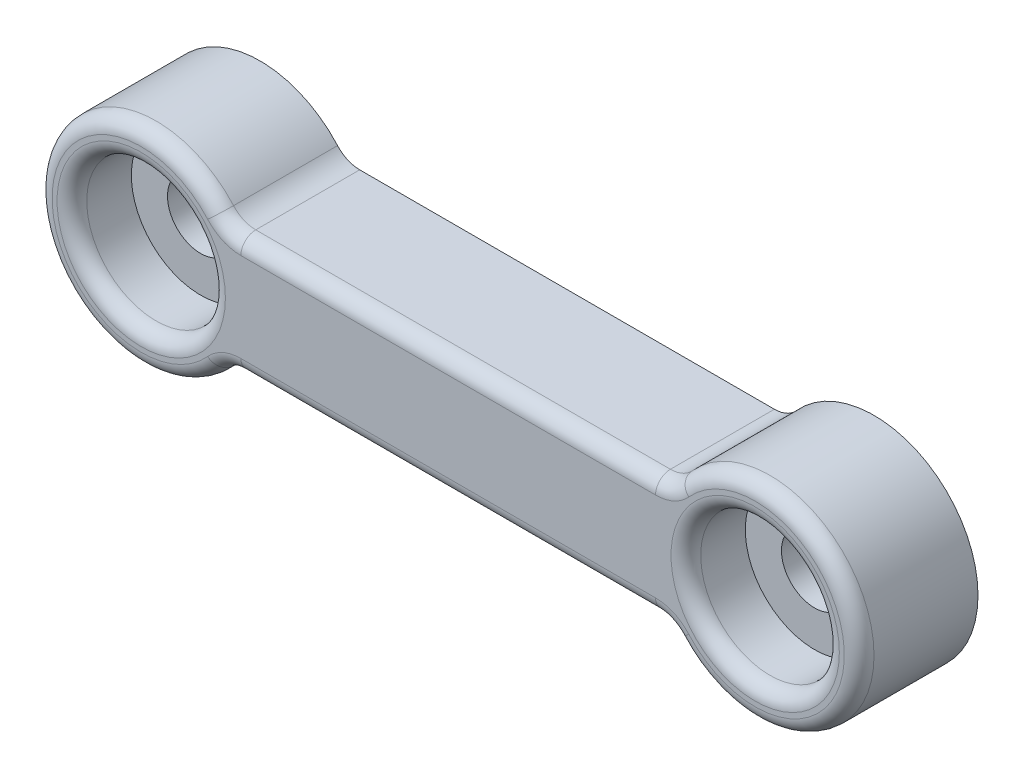
from build123d import *

# Parameters (mm, degrees)
SKETCH1_R           = 1.675
BOSS_EXTRUDE1_DEPTH = 6
SKETCH2_R           = 3.5
CUT_EXTRUDE1_DEPTH  = 3
FILLET1_R           = 0.75


with BuildPart() as part:
    # Sketch1 → Boss-Extrude1 (new body)
    with BuildSketch(Plane.XY):
        with BuildLine():
            Line((-10.468847051, 3), (10.468847051, 3))
            ThreePointArc((10.468847051, 3), (11.081219486, 3.130693606), (11.586881039, 3.5))
            ThreePointArc((11.586881039, 3.5), (20.75, 0), (11.586881039, -3.5))
            ThreePointArc((11.586881039, -3.5), (11.081219486, -3.130693606), (10.468847051, -3))
            Line((10.468847051, -3), (-10.468847051, -3))
            ThreePointArc((-10.468847051, -3), (-11.081219486, -3.130693606), (-11.586881039, -3.5))
            ThreePointArc((-11.586881039, -3.5), (-20.75, 0), (-11.586881039, 3.5))
            ThreePointArc((-11.586881039, 3.5), (-11.081219486, 3.130693606), (-10.468847051, 3))
        make_face()
        with Locations((15.5, 0)):
            Circle(SKETCH1_R, mode=Mode.SUBTRACT)
        with Locations((-15.5, 0)):
            Circle(SKETCH1_R, mode=Mode.SUBTRACT)
    extrude(amount=BOSS_EXTRUDE1_DEPTH)

    # Sketch2 → Cut-Extrude1 (cut)
    with BuildSketch(Plane.XY.offset(6)):
        with Locations((-15.5, 0)):
            Circle(SKETCH2_R)
        with Locations((15.5, 0)):
            Circle(SKETCH2_R)
    extrude(amount=-CUT_EXTRUDE1_DEPTH, mode=Mode.SUBTRACT)

    # Fillet1
    fillet1_edges = [part.edges().sort_by_distance(p)[0] for p in [
        (11.081219486, 3.130693606, 6),
        (0, 3, 6),
        (-11.081219486, 3.130693606, 6),
        (-20.75, 0, 6),
        (-11.081219486, -3.130693606, 6),
        (0, -3, 6),
        (-19, 0, 6),
        (12, 0, 6),
        (11.081219486, -3.130693606, 6),
        (20.75, 0, 6),
    ]]
    fillet(fillet1_edges, radius=FILLET1_R)


solid = part.part
